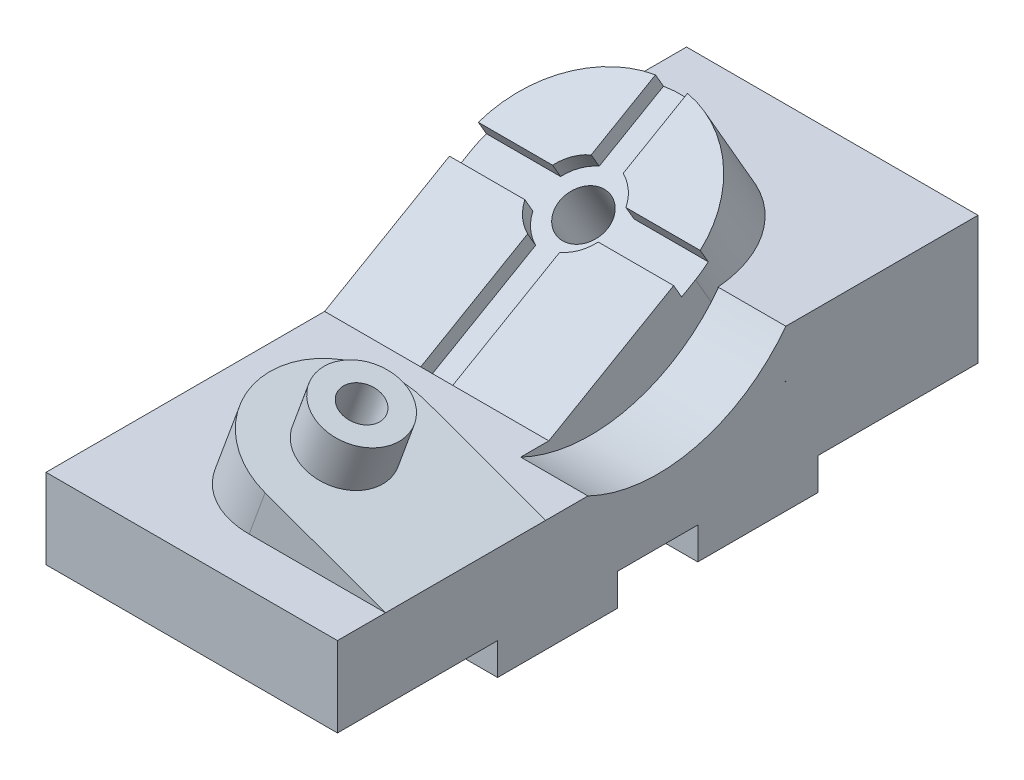
from build123d import *

# Parameters (mm, degrees)
SKETCH1_W               = 50
SKETCH1_H               = 91
SKETCH1_W_2             = 37.5
SKETCH1_W_3             = 25
BOSS_EXTRUDE1_DEPTH     = 25
SKETCH1_3_W             = 37.5
SKETCH1_3_H             = 91
BOSS_EXTRUDE2_DEPTH     = 35
BOSS_EXTRUDE3_REACH     = 66.013
SKETCH4_R               = 12.5
SKETCH4_R_2             = 6
SKETCH4_4_R             = 6
CUT_EXTRUDE1_DEPTH      = 65.01307477
SKETCH4_5_R             = 12.5
SKETCH4_5_R_2           = 6
BOSS_EXTRUDE4_DEPTH     = 15
SKETCH5_W               = 91
SKETCH5_H               = 60
BOSS_EXTRUDE5_DEPTH     = 15
CUT_EXTRUDE2_DEPTH      = 1
CUT_EXTRUDE2_DEPTH_BACK = 21
EXTRUDE_THIN1_DEPTH     = 21
BOSS_EXTRUDE6_REACH     = 88.811
SKETCH9_R               = 7.5
CUT_EXTRUDE4_DEPTH      = 5
SKETCH9_6_R             = 12.5
CUT_EXTRUDE5_DEPTH      = 5
SKETCH9_7_R             = 7.5
CUT_EXTRUDE6_DEPTH      = 87.810889132


with BuildPart() as part:
    # Sketch1 → Boss-Extrude1 (new body)
    with BuildSketch(Plane(origin=(0, 0, 0), x_dir=(0, 0, -1), z_dir=(0, 1, 0))):
        with Locations((25, 45.5)):
            Rectangle(SKETCH1_W, SKETCH1_H)
        with Locations((68.75, 45.5)):
            Rectangle(SKETCH1_W_2, SKETCH1_H)
        with Locations((100, 45.5)):
            Rectangle(SKETCH1_W_3, SKETCH1_H)
        with Locations((131.25, 45.5)):
            Rectangle(SKETCH1_W_2, SKETCH1_H)
        with Locations((175, 45.5)):
            Rectangle(SKETCH1_W, SKETCH1_H)
    extrude(amount=-BOSS_EXTRUDE1_DEPTH)

    # Sketch1_3 → Boss-Extrude2 (add)
    with BuildSketch(Plane(origin=(0, 0, 0), x_dir=(0, 0, -1), z_dir=(0, 1, 0))):
        with Locations((68.75, 45.5)):
            Rectangle(SKETCH1_3_W, SKETCH1_3_H)
        with Locations((131.25, 45.5)):
            Rectangle(SKETCH1_3_W, SKETCH1_3_H)
    extrude(amount=-BOSS_EXTRUDE2_DEPTH)

    # Boss-Extrude3: up to this face of the body (flat: up to its plane)
    boss_extrude3_end = Plane(part.part.faces().sort_by_distance((-45.5, 0, -100))[0])
    # Sketch4 → Boss-Extrude3 (add, up to the picked face)
    with BuildSketch(Plane(origin=(0, 0, 0), x_dir=(0.939692621, -0.342020143, 0), z_dir=(0.342020143, 0.939692621, 0)), mode=Mode.PRIVATE) as boss_extrude3_sk1:
        with BuildLine():
            ThreePointArc((-40, 15), (-65, 40), (-40, 65))
            Line((-40, 65), (0, 65))
            Line((0, 65), (0, 15))
            Line((0, 15), (-40, 15))
        make_face()
        with Locations((-40, 40)):
            Circle(SKETCH4_R, mode=Mode.SUBTRACT)
    boss_extrude3_tool1 = split(extrude(boss_extrude3_sk1.sketch, amount=-BOSS_EXTRUDE3_REACH, mode=Mode.PRIVATE), bisect_by=boss_extrude3_end, keep=Keep.BOTH, mode=Mode.PRIVATE)
    add(boss_extrude3_tool1.solids().sort_by_distance((-60.309415, 21.950832, -40))[0])
    # Sketch4 → Boss-Extrude3 (add, up to the picked face)
    with BuildSketch(Plane(origin=(0, 0, 0), x_dir=(0.939692621, -0.342020143, 0), z_dir=(0.342020143, 0.939692621, 0)), mode=Mode.PRIVATE) as boss_extrude3_sk2:
        with Locations((-40, 40)):
            Circle(SKETCH4_R)
        with Locations((-40, 40)):
            Circle(SKETCH4_R_2, mode=Mode.SUBTRACT)
    boss_extrude3_tool2 = split(extrude(boss_extrude3_sk2.sketch, amount=-BOSS_EXTRUDE3_REACH, mode=Mode.PRIVATE), bisect_by=boss_extrude3_end, keep=Keep.BOTH, mode=Mode.PRIVATE)
    add(boss_extrude3_tool2.solids().sort_by_distance((-49.001631, 17.835135, -40))[0])

    # Sketch4_4 → Cut-Extrude1 (cut, through all)
    with BuildSketch(Plane(origin=(0, 0, 0), x_dir=(0.939692621, -0.342020143, 0), z_dir=(0.342020143, 0.939692621, 0))):
        with Locations((-40, 40)):
            Circle(SKETCH4_4_R)
    extrude(amount=-CUT_EXTRUDE1_DEPTH, mode=Mode.SUBTRACT)

    # Sketch4_5 → Boss-Extrude4 (add)
    with BuildSketch(Plane(origin=(0, 0, 0), x_dir=(0.939692621, -0.342020143, 0), z_dir=(0.342020143, 0.939692621, 0))):
        with Locations((-40, 40)):
            Circle(SKETCH4_5_R)
        with Locations((-40, 40)):
            Circle(SKETCH4_5_R_2, mode=Mode.SUBTRACT)
    extrude(amount=BOSS_EXTRUDE4_DEPTH)

    # Sketch5 → Boss-Extrude5 (add)
    with BuildSketch(Plane(origin=(0, 0, 0), x_dir=(1, 0, 0), z_dir=(0, 1, 0))):
        with Locations((-45.5, 170)):
            Rectangle(SKETCH5_W, SKETCH5_H)
    extrude(amount=BOSS_EXTRUDE5_DEPTH)

    # Sketch6 → Cut-Extrude2 (cut, two sides)
    with BuildSketch(Plane(origin=(0, 0, 0), x_dir=(0, 0, -1), z_dir=(1, 0, 0))) as cut_extrude2_sk:
        with BuildLine():
            ThreePointArc((78.205505282, 0), (100, -5), (121.794494718, 0))
            Line((121.794494718, 0), (78.205505282, 0))
        make_face()
    extrude(amount=CUT_EXTRUDE2_DEPTH, mode=Mode.SUBTRACT)
    extrude(cut_extrude2_sk.sketch, amount=-CUT_EXTRUDE2_DEPTH_BACK, mode=Mode.SUBTRACT)

    # Sketch6_2 → Extrude-Thin1 (add)
    with BuildSketch(Plane(origin=(0, 0, 0), x_dir=(0, 0, -1), z_dir=(1, 0, 0))):
        with BuildLine():
            ThreePointArc((78.205505282, 0), (111.794494718, -3.588989435), (140, 15))
            Line((140, 15), (148, 9))
            ThreePointArc((148, 9), (114.153393661, -13.306787322), (73.846606339, -9))
            Line((73.846606339, -9), (78.205505282, 0))
        make_face()
    extrude(amount=-EXTRUDE_THIN1_DEPTH)

    # Sketch9 → Boss-Extrude6 (add, up to next)
    with BuildSketch(Plane(origin=(0, -37.672105065, -21.75), x_dir=(1, 0, 0), z_dir=(0, 0.866025404, 0.5)), mode=Mode.PRIVATE) as boss_extrude6_sk1:
        with BuildLine():
            Line((-21, 75.344210129), (-21, 125.344210129))
            ThreePointArc((-21, 125.344210129), (-56, 160.344210129), (-91, 125.344210129))
            Line((-91, 125.344210129), (-91, 75.344210129))
            Line((-91, 75.344210129), (-21, 75.344210129))
        make_face()
        with Locations((-56, 125.344210129)):
            Circle(SKETCH9_R, mode=Mode.SUBTRACT)
    boss_extrude6_tool1 = extrude(boss_extrude6_sk1.sketch, amount=-BOSS_EXTRUDE6_REACH, mode=Mode.PRIVATE) - part.part
    add(boss_extrude6_tool1.solids().sort_by_distance((-56, 19.386227, -120.577931))[0])

    # Sketch9_5 → Cut-Extrude4 (cut)
    with BuildSketch(Plane(origin=(0, -37.672105065, -21.75), x_dir=(1, 0, 0), z_dir=(0, 0.866025404, 0.5))):
        with BuildLine():
            Line((-44.543560763, 120.344210129), (-21, 120.344210129))
            Line((-21, 120.344210129), (-21, 125.344210129))
            ThreePointArc((-21, 125.344210129), (-21.08986132, 127.850645317), (-21.358983849, 130.344210129))
            Line((-21.358983849, 130.344210129), (-44.543560763, 130.344210129))
            ThreePointArc((-44.543560763, 130.344210129), (-43.5, 125.344210129), (-44.543560763, 120.344210129))
        make_face()
        with BuildLine():
            Line((-61, 75.344210129), (-51, 75.344210129))
            Line((-51, 75.344210129), (-51, 113.887770892))
            ThreePointArc((-51, 113.887770892), (-56, 112.844210129), (-61, 113.887770892))
            Line((-61, 113.887770892), (-61, 75.344210129))
        make_face()
        with BuildLine():
            Line((-51, 136.800649367), (-51, 159.985226281))
            ThreePointArc((-51, 159.985226281), (-56, 160.344210129), (-61, 159.985226281))
            Line((-61, 159.985226281), (-61, 136.800649367))
            ThreePointArc((-61, 136.800649367), (-56, 137.844210129), (-51, 136.800649367))
        make_face()
        with BuildLine():
            Line((-91, 125.344210129), (-91, 120.344210129))
            Line((-91, 120.344210129), (-67.456439237, 120.344210129))
            ThreePointArc((-67.456439237, 120.344210129), (-68.5, 125.344210129), (-67.456439237, 130.344210129))
            Line((-67.456439237, 130.344210129), (-90.641016151, 130.344210129))
            ThreePointArc((-90.641016151, 130.344210129), (-90.91013868, 127.850645317), (-91, 125.344210129))
        make_face()
    extrude(amount=-CUT_EXTRUDE4_DEPTH, mode=Mode.SUBTRACT)

    # Sketch9_6 → Cut-Extrude5 (cut)
    with BuildSketch(Plane(origin=(0, -37.672105065, -21.75), x_dir=(1, 0, 0), z_dir=(0, 0.866025404, 0.5))):
        with Locations((-56, 125.344210129)):
            Circle(SKETCH9_6_R)
    extrude(amount=-CUT_EXTRUDE5_DEPTH, mode=Mode.SUBTRACT)

    # Sketch9_7 → Cut-Extrude6 (cut, through all)
    with BuildSketch(Plane(origin=(0, -37.672105065, -21.75), x_dir=(1, 0, 0), z_dir=(0, 0.866025404, 0.5))):
        with Locations((-56, 125.344210129)):
            Circle(SKETCH9_7_R)
    extrude(amount=-CUT_EXTRUDE6_DEPTH, mode=Mode.SUBTRACT)


solid = part.part
